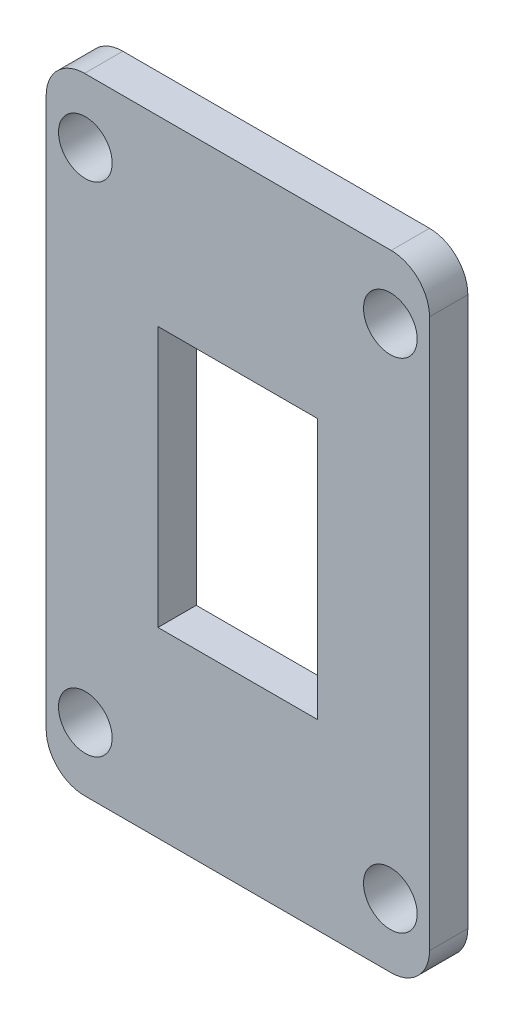
from build123d import *

# Parameters (mm, degrees)
SKETCH1_W           = 30
SKETCH1_H           = 48.96
SKETCH1_R           = 2.1
SKETCH1_W_2         = 12.5
SKETCH1_H_2         = 20.4
BOSS_EXTRUDE1_DEPTH = 3
FILLET1_R           = 3


with BuildPart() as part:
    # Sketch1 → Boss-Extrude1 (new body)
    with BuildSketch(Plane.XY):
        Rectangle(SKETCH1_W, SKETCH1_H)
        with Locations((-11.93627451, 19.48)):
            Circle(SKETCH1_R, mode=Mode.SUBTRACT)
        with Locations((11.93627451, 19.48)):
            Circle(SKETCH1_R, mode=Mode.SUBTRACT)
        with Locations((11.93627451, -19.48)):
            Circle(SKETCH1_R, mode=Mode.SUBTRACT)
        with Locations((-11.93627451, -19.48)):
            Circle(SKETCH1_R, mode=Mode.SUBTRACT)
        Rectangle(SKETCH1_W_2, SKETCH1_H_2, mode=Mode.SUBTRACT)
    extrude(amount=BOSS_EXTRUDE1_DEPTH)

    # Fillet1
    fillet1_edges = [part.edges().sort_by_distance(p)[0] for p in [
        (15, -24.48, 1.5),
        (-15, -24.48, 1.5),
        (-15, 24.48, 1.5),
        (15, 24.48, 1.5),
    ]]
    fillet(fillet1_edges, radius=FILLET1_R)


solid = part.part
